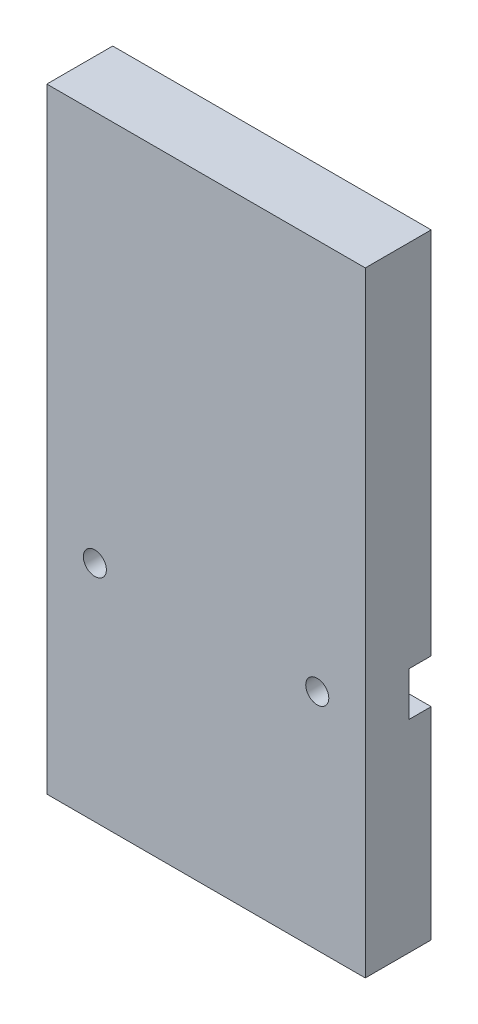
from build123d import *

# Parameters (mm, degrees)
SKETCH1_W                        = 184.15
SKETCH1_H                        = 38.1
BOSS_EXTRUDE1_DEPTH              = 355.6
SKETCH2_W                        = 184.15
SKETCH2_H                        = 25.4
CUT_EXTRUDE1_DEPTH               = 12.7
SKETCH3_R                        = 6.6675
CUT_EXTRUDE2_DEPTH               = 13.7
CUT_EXTRUDE2_DEPTH_BACK          = 26.4
F_10_0_1935_DIAMETER_HOLE1_D     = 4.9149
F_10_0_1935_DIAMETER_HOLE1_DEPTH = 76.2
F_10_0_1935_DIAMETER_HOLE1_TIP   = 1.476584928


with BuildPart() as part:
    # Sketch1 → Boss-Extrude1 (new body)
    with BuildSketch(Plane(origin=(0, 0, 0), x_dir=(1, 0, 0), z_dir=(0, 1, 0))):
        with Locations((92.075, 19.05)):
            Rectangle(SKETCH1_W, SKETCH1_H)
    extrude(amount=BOSS_EXTRUDE1_DEPTH)

    # Sketch2 → Cut-Extrude1 (cut)
    with BuildSketch(Plane.XY.offset(-38.1)):
        with Locations((92.075, 129.54)):
            Rectangle(SKETCH2_W, SKETCH2_H)
    extrude(amount=CUT_EXTRUDE1_DEPTH, mode=Mode.SUBTRACT)

    # Sketch3 → Cut-Extrude2 (cut, two sides)
    with BuildSketch(Plane(origin=(0, 0, -25.4), x_dir=(-1, 0, 0), z_dir=(0, 0, -1))) as cut_extrude2_sk:
        with Locations((-156.37405606, 129.54)):
            Circle(SKETCH3_R)
        with Locations((-27.77594394, 129.54)):
            Circle(SKETCH3_R)
    extrude(amount=CUT_EXTRUDE2_DEPTH, mode=Mode.SUBTRACT)
    extrude(cut_extrude2_sk.sketch, amount=-CUT_EXTRUDE2_DEPTH_BACK, mode=Mode.SUBTRACT)

    # #10 (0.1935) Diameter Hole1
    with Locations(Plane(origin=(12.7, 0, -19.05), x_dir=(0, 0, -1), z_dir=(0, -1, 0))):
        with Locations((0, 0), (0, 22.678571429), (0, 45.357142857), (0, 68.035714286), (0, 90.714285714), (0, 113.392857143), (0, 136.071428571), (0, 158.75)):
            Hole(F_10_0_1935_DIAMETER_HOLE1_D / 2, depth=F_10_0_1935_DIAMETER_HOLE1_DEPTH)
            with Locations((0, 0, -(F_10_0_1935_DIAMETER_HOLE1_DEPTH + F_10_0_1935_DIAMETER_HOLE1_TIP / 2))):  # 118° drill point
                Cone(0, F_10_0_1935_DIAMETER_HOLE1_D / 2, F_10_0_1935_DIAMETER_HOLE1_TIP, mode=Mode.SUBTRACT)


solid = part.part
